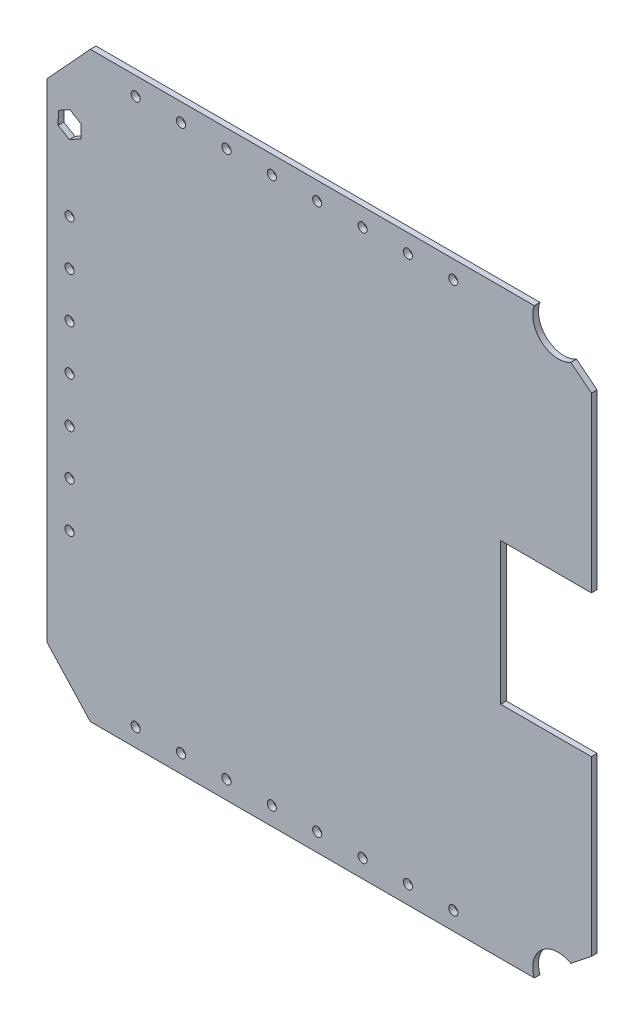
from build123d import *

# Parameters (mm, degrees)
BOSS_EXTRUDE1_DEPTH = 3.175
SKETCH2_R           = 2.5527
CUT_EXTRUDE1_DEPTH  = 4.175
CUT_EXTRUDE2_DEPTH  = 4.175
SKETCH4_R           = 2.5527
CUT_EXTRUDE3_DEPTH  = 4.175


with BuildPart() as part:
    # Sketch1 → Boss-Extrude1 (new body)
    with BuildSketch(Plane.XY):
        with BuildLine():
            Line((-152.4, 136.525), (-128.098009656, 162.977004026))
            Line((-128.098009656, 162.977004026), (120.423210344, 162.977004026))
            ThreePointArc((120.423210344, 162.977004026), (124.628339443, 147.208762232), (140.874895001, 145.669284239))
            Line((140.874895001, 145.669284239), (152.4, 136.525))
            Line((152.4, 136.525), (152.4, 39.6875))
            Line((152.4, 39.6875), (101.6, 39.6875))
            Line((101.6, 39.6875), (101.6, -39.6875))
            Line((101.6, -39.6875), (152.4, -39.6875))
            Line((152.4, -39.6875), (152.4, -136.525))
            Line((152.4, -136.525), (140.874895001, -145.669284239))
            ThreePointArc((140.874895001, -145.669284239), (124.628339443, -147.208762232), (120.423210344, -162.977004026))
            Line((120.423210344, -162.977004026), (-128.098009656, -162.977004026))
            Line((-128.098009656, -162.977004026), (-152.4, -136.525))
            Line((-152.4, -136.525), (-152.4, 136.525))
        make_face()
    extrude(amount=BOSS_EXTRUDE1_DEPTH)

    # Sketch2 → Cut-Extrude1 (cut, through all)
    with BuildSketch(Plane.XY.offset(3.175)):
        with Locations((-102.698009656, 152.829704026)):
            Circle(SKETCH2_R)
        with Locations((-77.298009656, 152.829704026)):
            Circle(SKETCH2_R)
        with Locations((-51.898009656, 152.829704026)):
            Circle(SKETCH2_R)
        with Locations((-26.498009656, 152.829704026)):
            Circle(SKETCH2_R)
        with Locations((-1.098009656, 152.829704026)):
            Circle(SKETCH2_R)
        with Locations((24.301990344, 152.829704026)):
            Circle(SKETCH2_R)
        with Locations((49.701990344, 152.829704026)):
            Circle(SKETCH2_R)
        with Locations((75.101990344, 152.829704026)):
            Circle(SKETCH2_R)
        with Locations((-51.898009656, -152.829704026)):
            Circle(SKETCH2_R)
        with Locations((-77.298009656, -152.829704026)):
            Circle(SKETCH2_R)
        with Locations((-102.698009656, -152.829704026)):
            Circle(SKETCH2_R)
        with Locations((-26.498009656, -152.829704026)):
            Circle(SKETCH2_R)
        with Locations((-1.098009656, -152.829704026)):
            Circle(SKETCH2_R)
        with Locations((24.301990344, -152.829704026)):
            Circle(SKETCH2_R)
        with Locations((49.701990344, -152.829704026)):
            Circle(SKETCH2_R)
        with Locations((75.101990344, -152.829704026)):
            Circle(SKETCH2_R)
    extrude(amount=-CUT_EXTRUDE1_DEPTH, mode=Mode.SUBTRACT)

    # Sketch3 → Cut-Extrude2 (cut, through all)
    with BuildSketch(Plane.XY.offset(3.175)):
        Polygon((-133.286983573, 124.204793052), (-139.572032875, 127.981231667), (-145.985049302, 124.426438614), (-146.113016427, 117.095206948), (-139.827967125, 113.318768333), (-133.414950698, 116.873561386), align=None)
    extrude(amount=-CUT_EXTRUDE2_DEPTH, mode=Mode.SUBTRACT)

    # Sketch4 → Cut-Extrude3 (cut, through all)
    with BuildSketch(Plane(origin=(0, 0, 0), x_dir=(-1, 0, 0), z_dir=(0, 0, -1))):
        with Locations((139.7, 76.2)):
            Circle(SKETCH4_R)
        with Locations((139.7, 50.8)):
            Circle(SKETCH4_R)
        with Locations((139.7, 25.4)):
            Circle(SKETCH4_R)
        with Locations((139.7, 0)):
            Circle(SKETCH4_R)
        with Locations((139.7, -25.4)):
            Circle(SKETCH4_R)
        with Locations((139.7, -50.8)):
            Circle(SKETCH4_R)
        with Locations((139.7, -76.2)):
            Circle(SKETCH4_R)
    extrude(amount=-CUT_EXTRUDE3_DEPTH, mode=Mode.SUBTRACT)


solid = part.part
